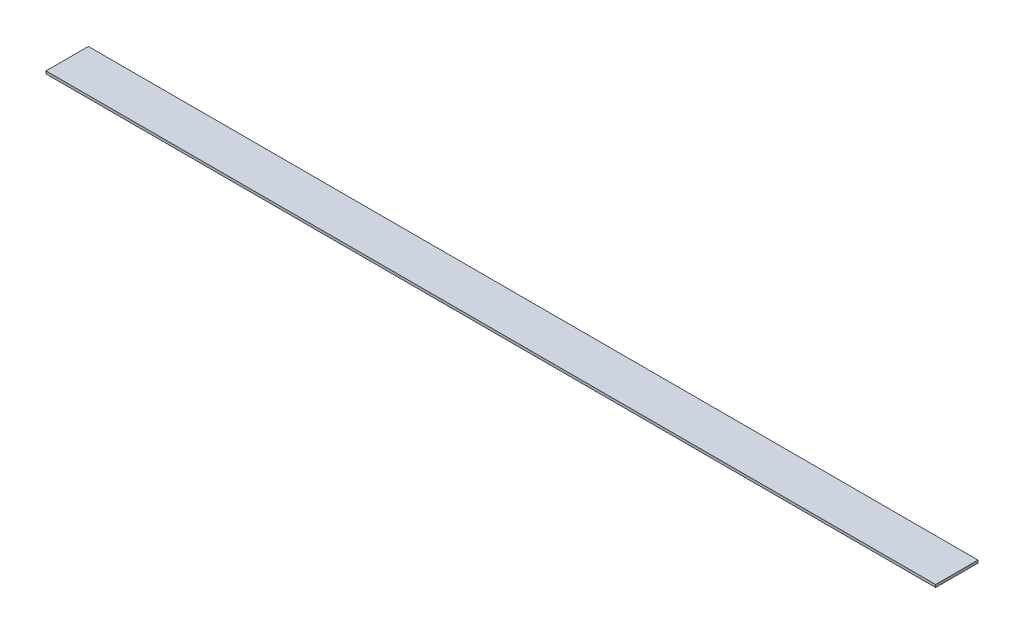
from build123d import *

# Parameters (mm, degrees)
SKETCH1_W           = 533.4
SKETCH1_H           = 25.4
BOSS_EXTRUDE1_DEPTH = 1.5875


with BuildPart() as part:
    # Sketch1 → Boss-Extrude1 (new body)
    with BuildSketch(Plane(origin=(0, 0, 0), x_dir=(1, 0, 0), z_dir=(0, 1, 0))):
        with Locations((266.7, 12.7)):
            Rectangle(SKETCH1_W, SKETCH1_H)
    extrude(amount=BOSS_EXTRUDE1_DEPTH)


solid = part.part
